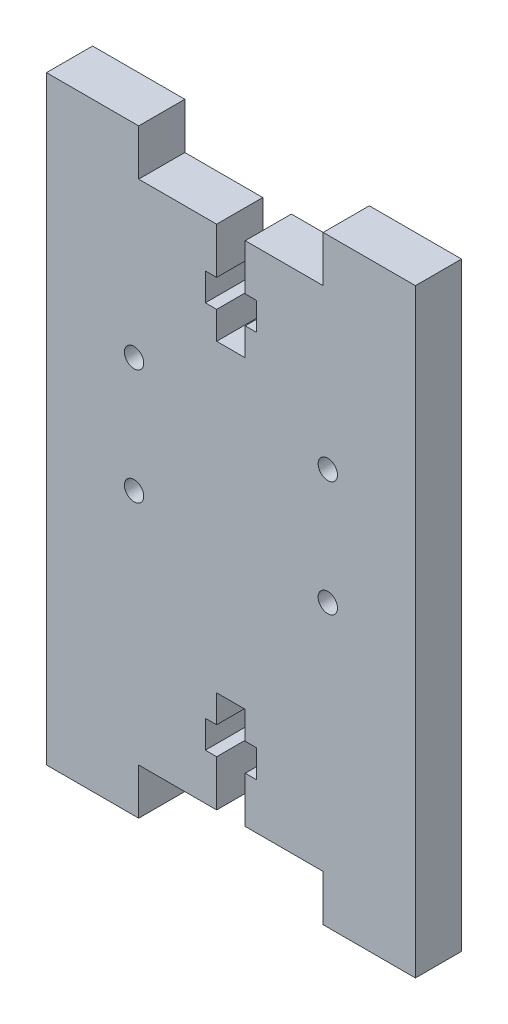
from build123d import *

# Parameters (mm, degrees)
ESQUISSE1_W             = 40
ESQUISSE1_H             = 62
BOSS_EXTRU_1_DEPTH      = 5
ESQUISSE2_W             = 20
ESQUISSE2_H             = 3.5
ENL_V_MAT_EXTRU_1_DEPTH = 6
ESQUISSE3_W             = 20
ESQUISSE3_H             = 3.5
ENL_V_MAT_EXTRU_2_DEPTH = 6
ESQUISSE8_W             = 3.1
ESQUISSE8_H             = 3
ESQUISSE8_H_2           = 5
ESQUISSE8_W_2           = 1.225
ENL_V_MAT_EXTRU_3_DEPTH = 6
ESQUISSE9_W             = 10
ESQUISSE9_H             = 65
BOSS_EXTRU_2_DEPTH      = 5
ESQUISSE10_R            = 1.05
ENL_V_MAT_EXTRU_4_DEPTH = 6


with BuildPart() as part:
    # Esquisse1 → Boss.-Extru.1 (new body)
    with BuildSketch(Plane.XY.offset(5)):
        Rectangle(ESQUISSE1_W, ESQUISSE1_H)
    extrude(amount=-BOSS_EXTRU_1_DEPTH)

    # Esquisse2 → Enlèv. mat.-Extru.1 (cut, through all)
    with BuildSketch(Plane(origin=(0, 0, 0), x_dir=(-1, 0, 0), z_dir=(0, 0, -1))):
        with Locations((0, 29.25)):
            Rectangle(ESQUISSE2_W, ESQUISSE2_H)
    extrude(amount=-ENL_V_MAT_EXTRU_1_DEPTH, mode=Mode.SUBTRACT)

    # Esquisse3 → Enlèv. mat.-Extru.2 (cut, through all)
    with BuildSketch(Plane(origin=(0, 0, 0), x_dir=(-1, 0, 0), z_dir=(0, 0, -1))):
        with Locations((0, -29.25)):
            Rectangle(ESQUISSE3_W, ESQUISSE3_H)
    extrude(amount=-ENL_V_MAT_EXTRU_2_DEPTH, mode=Mode.SUBTRACT)

    # Esquisse8 → Enlèv. mat.-Extru.3 (cut, through all)
    with BuildSketch(Plane.XY.offset(5)):
        with Locations((0, 21)):
            Rectangle(ESQUISSE8_W, ESQUISSE8_H)
        with Locations((0, 25)):
            Rectangle(ESQUISSE8_W, ESQUISSE8_H_2)
        with Locations((-2.1625, 21)):
            Rectangle(ESQUISSE8_W_2, ESQUISSE8_H)
        with Locations((2.1625, 21)):
            Rectangle(ESQUISSE8_W_2, ESQUISSE8_H)
        with Locations((0, 18)):
            Rectangle(ESQUISSE8_W, ESQUISSE8_H)
        with Locations((0, -18)):
            Rectangle(ESQUISSE8_W, ESQUISSE8_H)
        with Locations((-2.1625, -21)):
            Rectangle(ESQUISSE8_W_2, ESQUISSE8_H)
        with Locations((0, -21)):
            Rectangle(ESQUISSE8_W, ESQUISSE8_H)
        with Locations((2.1625, -21)):
            Rectangle(ESQUISSE8_W_2, ESQUISSE8_H)
        with Locations((0, -25)):
            Rectangle(ESQUISSE8_W, ESQUISSE8_H_2)
    extrude(amount=-ENL_V_MAT_EXTRU_3_DEPTH, mode=Mode.SUBTRACT)

    # Esquisse9 → Boss.-Extru.2 (add)
    with BuildSketch(Plane.XY.offset(5)):
        with Locations((-15, 0)):
            Rectangle(ESQUISSE9_W, ESQUISSE9_H)
        with Locations((15, 0)):
            Rectangle(ESQUISSE9_W, ESQUISSE9_H)
    extrude(amount=-BOSS_EXTRU_2_DEPTH)

    # Esquisse10 → Enlèv. mat.-Extru.4 (cut, through all)
    with BuildSketch(Plane(origin=(0, 0, 0), x_dir=(-1, 0, 0), z_dir=(0, 0, -1))):
        with Locations((-10.5, 10.5)):
            Circle(ESQUISSE10_R)
        with Locations((10.5, 10.5)):
            Circle(ESQUISSE10_R)
        with Locations((10.5, -2)):
            Circle(ESQUISSE10_R)
        with Locations((-10.5, -2)):
            Circle(ESQUISSE10_R)
    extrude(amount=-ENL_V_MAT_EXTRU_4_DEPTH, mode=Mode.SUBTRACT)


solid = part.part
